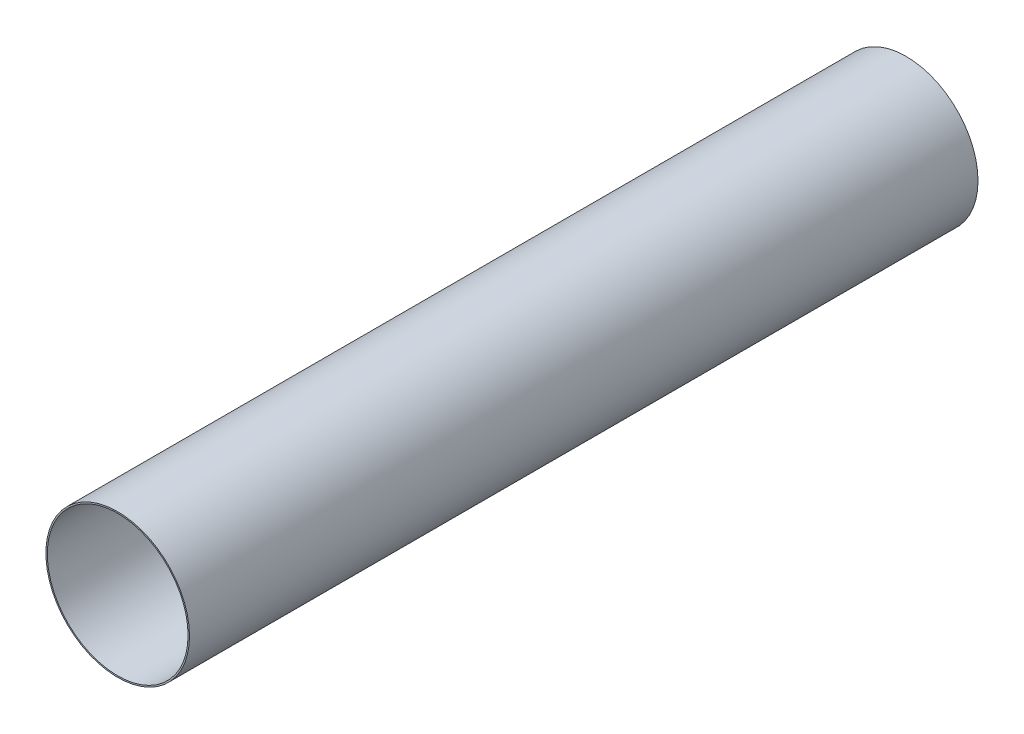
from build123d import *

# Parameters (mm, degrees)
SKETCH1_R           = 32.385
SKETCH1_R_2         = 31.75
BOSS_EXTRUDE1_DEPTH = 355.6


with BuildPart() as part:
    # Sketch1 → Boss-Extrude1 (new body)
    with BuildSketch(Plane.XY):
        Circle(SKETCH1_R)
        Circle(SKETCH1_R_2, mode=Mode.SUBTRACT)
    extrude(amount=BOSS_EXTRUDE1_DEPTH)


solid = part.part
